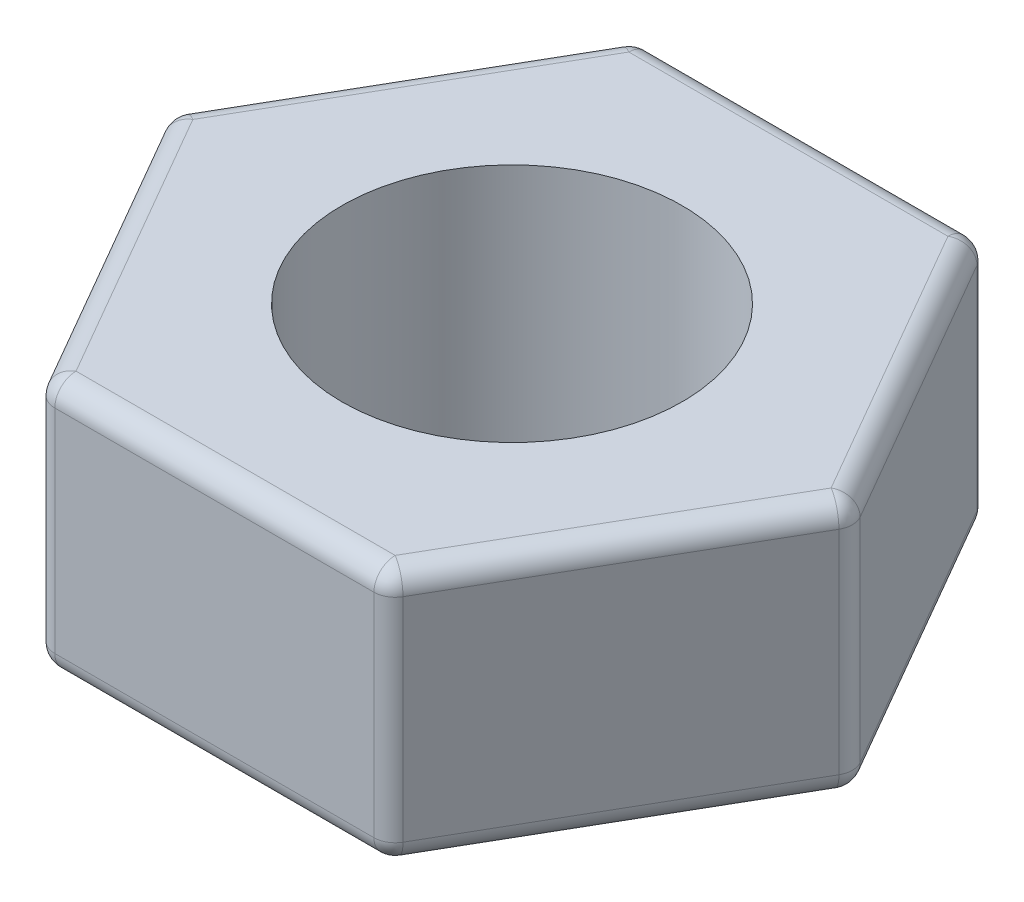
from build123d import *

# Parameters (mm, degrees)
SKETCH1_R           = 2
BOSS_EXTRUDE1_DEPTH = 3
FILLET1_R           = 0.25


with BuildPart() as part:
    # Sketch1 → Boss-Extrude1 (new body)
    with BuildSketch(Plane(origin=(0, 0, 0), x_dir=(1, 0, 0), z_dir=(0, 1, 0))):
        Polygon((-2.020725942, 3.5), (-4.041451884, 0), (-2.020725942, -3.5), (2.020725942, -3.5), (4.041451884, 0), (2.020725942, 3.5), align=None)
        Circle(SKETCH1_R, mode=Mode.SUBTRACT)
    extrude(amount=BOSS_EXTRUDE1_DEPTH)

    # Fillet1
    fillet1_edges = [part.edges().sort_by_distance(p)[0] for p in [
        (2.020725942, 1.5, -3.5),
        (4.041451884, 1.5, 0),
        (2.020725942, 1.5, 3.5),
        (-2.020725942, 1.5, 3.5),
        (-4.041451884, 1.5, 0),
        (-2.020725942, 1.5, -3.5),
        (-3.031088913, 3, 1.75),
        (0, 3, 3.5),
        (3.031088913, 3, 1.75),
        (3.031088913, 3, -1.75),
        (0, 3, -3.5),
        (3.031088913, 0, -1.75),
        (3.031088913, 0, 1.75),
        (0, 0, 3.5),
        (-3.031088913, 0, 1.75),
        (-3.031088913, 0, -1.75),
        (0, 0, -3.5),
        (-3.031088913, 3, -1.75),
    ]]
    fillet(fillet1_edges, radius=FILLET1_R)


solid = part.part
